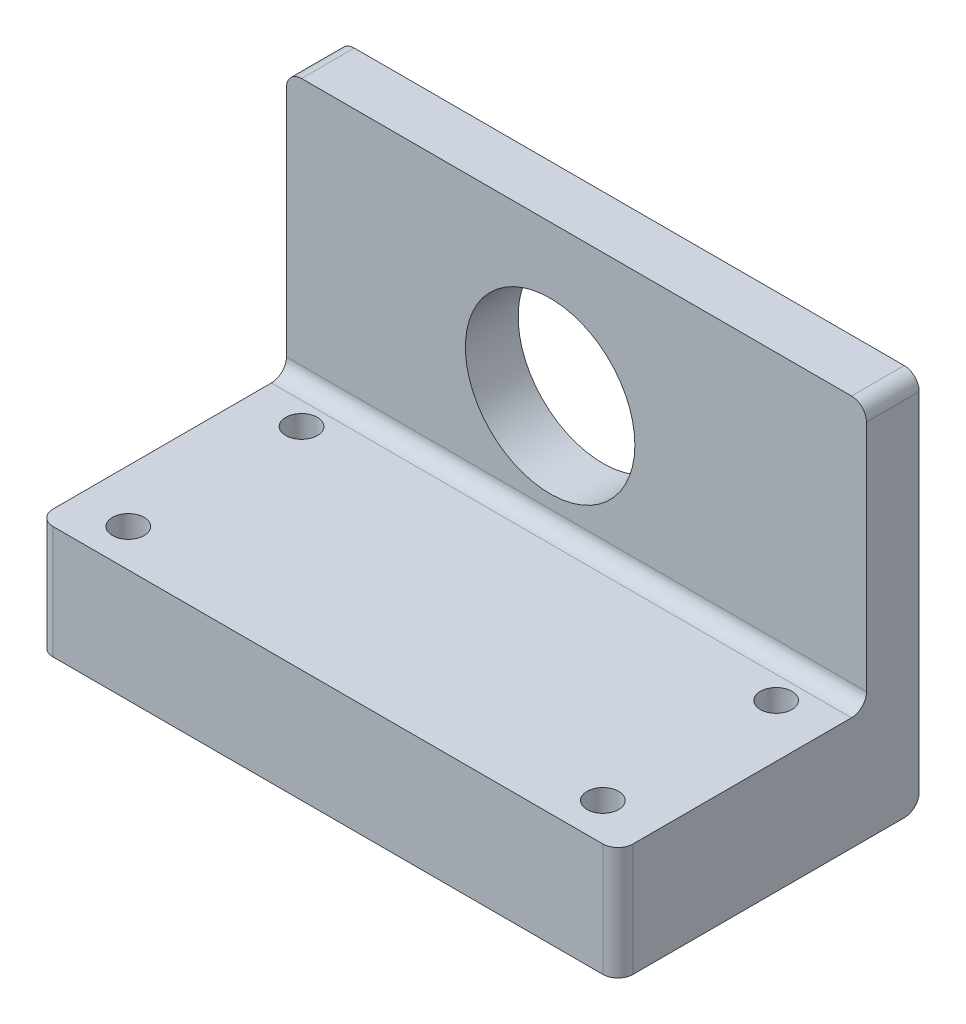
from build123d import *

# Parameters (mm, degrees)
SKETCH1_W           = 77
SKETCH1_H           = 35
BOSS_EXTRUDE1_DEPTH = 7
SKETCH2_R           = 11.25
CUT_EXTRUDE1_DEPTH  = 15
SKETCH3_W           = 77
SKETCH3_H           = 15
BOSS_EXTRUDE2_DEPTH = 40
SKETCH4_R           = 2.1
CUT_EXTRUDE2_DEPTH  = 20
FILLET1_R           = 2
FILLET2_R           = 2


with BuildPart() as part:
    # Sketch1 → Boss-Extrude1 (new body)
    with BuildSketch(Plane.XY):
        with Locations((3.5, 0)):
            Rectangle(SKETCH1_W, SKETCH1_H)
    extrude(amount=BOSS_EXTRUDE1_DEPTH)

    # Sketch2 → Cut-Extrude1 (cut)
    with BuildSketch(Plane.XY.offset(7)):
        with Locations((0, -2.5)):
            Circle(SKETCH2_R)
    extrude(amount=-CUT_EXTRUDE1_DEPTH, mode=Mode.SUBTRACT)

    # Sketch3 → Boss-Extrude2 (add)
    with BuildSketch(Plane(origin=(0, 0, 0), x_dir=(-1, 0, 0), z_dir=(0, 0, -1))):
        with Locations((-3.5, -25)):
            Rectangle(SKETCH3_W, SKETCH3_H)
    extrude(amount=-BOSS_EXTRUDE2_DEPTH)

    # Sketch4 → Cut-Extrude2 (cut)
    with BuildSketch(Plane(origin=(0, -17.5, 0), x_dir=(1, 0, 0), z_dir=(0, 1, 0))):
        with Locations((-28, -35)):
            Circle(SKETCH4_R)
        with Locations((-28, -12)):
            Circle(SKETCH4_R)
        with Locations((35, -35)):
            Circle(SKETCH4_R)
        with Locations((35, -12)):
            Circle(SKETCH4_R)
    extrude(amount=-CUT_EXTRUDE2_DEPTH, mode=Mode.SUBTRACT)

    # Fillet1
    fillet1_edges = [part.edges().sort_by_distance(p)[0] for p in [
        (3.5, -17.5, 7),
    ]]
    fillet(fillet1_edges, radius=FILLET1_R)

    # Fillet2
    fillet2_edges = [part.edges().sort_by_distance(p)[0] for p in [
        (42, -25, 40),
        (-35, -25, 40),
        (3.5, -32.5, 0),
        (-35, 17.5, 3.5),
        (42, 17.5, 3.5),
    ]]
    fillet(fillet2_edges, radius=FILLET2_R)


solid = part.part
